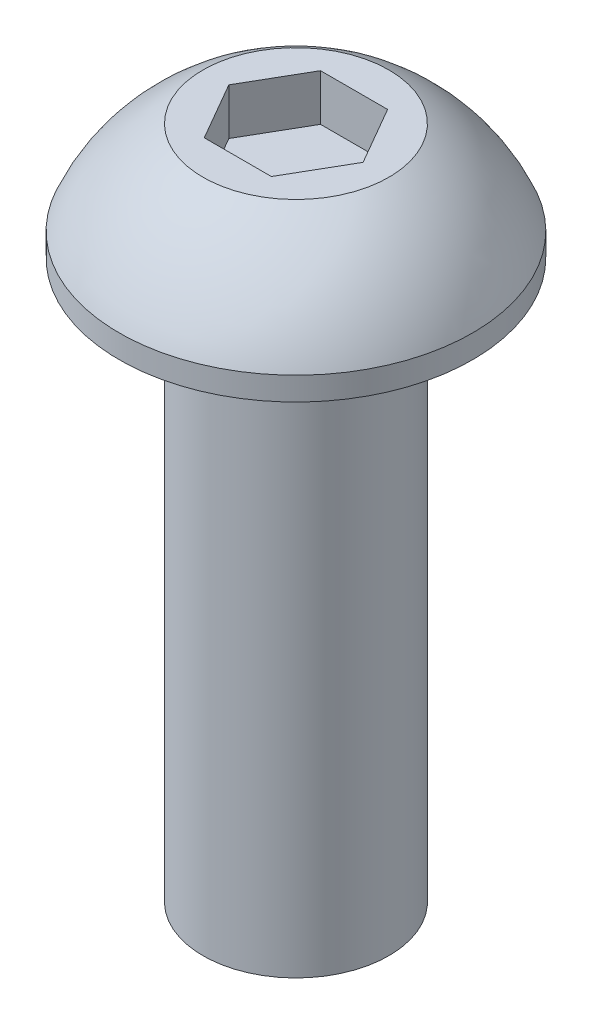
from build123d import *

# Parameters (mm, degrees)
CUT_EXTRUDE1_DEPTH = 1


with BuildPart() as part:
    # Sketch1 → Revolve1 (revolve)
    with BuildSketch(Plane.XY):
        with BuildLine():
            Line((2, 0), (3.8, 0))
            Line((3.8, 0), (3.8, 0.5))
            ThreePointArc((3.8, 0.5), (3.073216049, 1.655894444), (2, 2.5))
            Line((2, 2.5), (0, 2.5))
            Line((0, 2.5), (0, -12))
            Line((0, -12), (2, -12))
            Line((2, -12), (2, 0))
        make_face()
    revolve(axis=Axis((0, -12, 0), (0, 1, 0)))

    # Sketch2 → Cut-Extrude1 (cut)
    with BuildSketch(Plane(origin=(0, 2.5, 0), x_dir=(1, 0, 0), z_dir=(0, 1, 0))):
        Polygon((0.721687836, 1.25), (-0.721687836, 1.25), (-1.443375673, 0), (-0.721687836, -1.25), (0.721687836, -1.25), (1.443375673, 0), align=None)
    extrude(amount=-CUT_EXTRUDE1_DEPTH, mode=Mode.SUBTRACT)


solid = part.part
